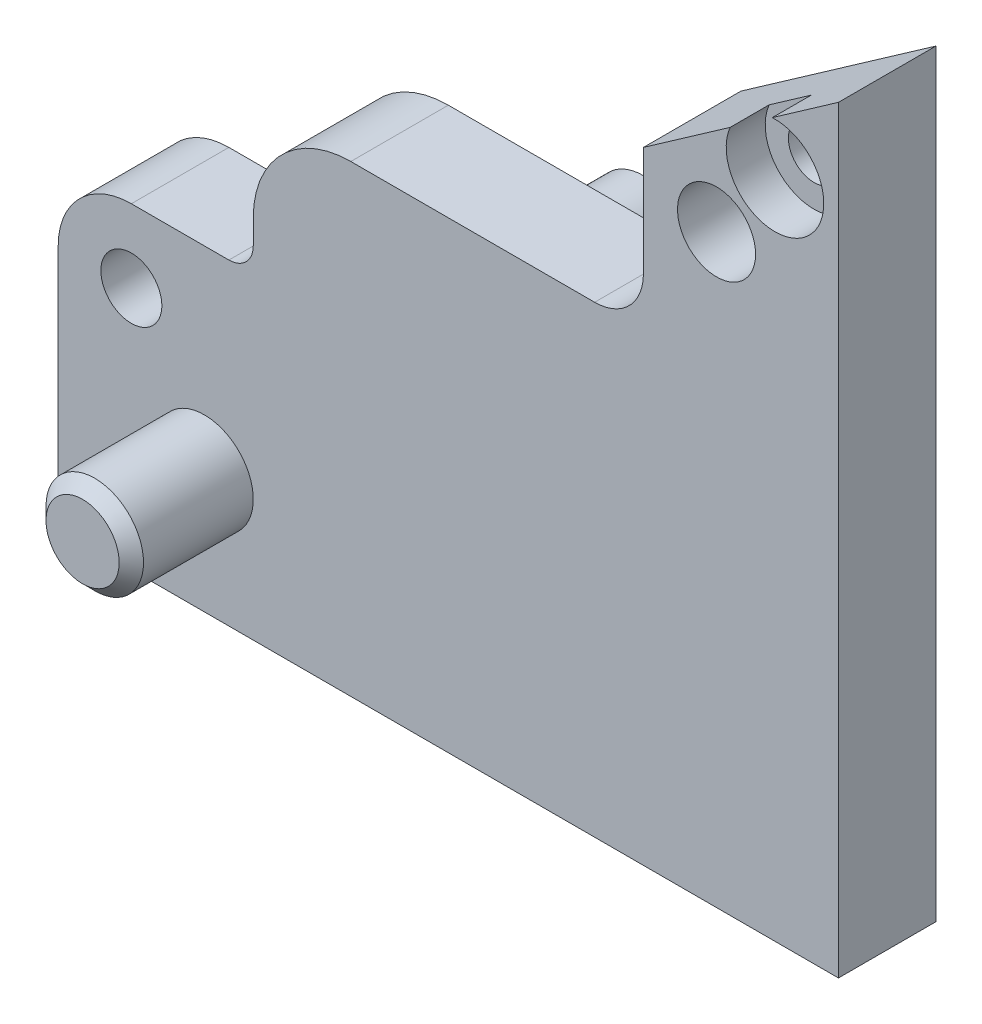
from build123d import *

# Parameters (mm, degrees)
SKETCH1_W                       = 32
SKETCH1_H                       = 31.101660306
BOSS_EXTRUDE1_DEPTH             = 4
SKETCH2_W                       = 8
SKETCH2_H                       = 18.101660306
CUT_EXTRUDE1_DEPTH              = 5
SKETCH3_W                       = 16
SKETCH3_H                       = 12.101660306
CUT_EXTRUDE2_DEPTH              = 5
DRAFT1_ANGLE                    = -35.000000002
SKETCH4_W                       = 2
SKETCH4_H                       = 5
SKETCH5_W                       = 2
SKETCH5_H                       = 5
F_3_2_3_2_DIAMETER_HOLE1_D      = 3.2
F_3_2_3_2_DIAMETER_HOLE1_DEPTH  = 9
F_2_5_2_5_DIAMETER_HOLE1_D      = 2.5
F_2_5_2_5_DIAMETER_HOLE1_DEPTH  = 9
M4X0_7_TAPPED_HOLE1_D           = 2.1
M4X0_7_TAPPED_HOLE1_DEPTH       = 9
M4X0_7_TAPPED_HOLE1_CBORE_D     = 4
M4X0_7_TAPPED_HOLE1_CBORE_DEPTH = 1.6
F_2_5_2_5_DIAMETER_HOLE2_D      = 2.5
F_2_5_2_5_DIAMETER_HOLE2_DEPTH  = 7.5
F_2_5_2_5_DIAMETER_HOLE2_TIP    = 0.751075774
CHAMFER1_SIZE                   = 0.5
FILLET1_R                       = 1
FILLET2_R                       = 2
FILLET3_R                       = 3
FILLET4_R                       = 4


with BuildPart() as part:
    # Sketch1 → Boss-Extrude1 (new body)
    with BuildSketch(Plane(origin=(0, 0, 0), x_dir=(-1, 0, 0), z_dir=(0, 0, -1))):
        with Locations((-16, 15.550830153)):
            Rectangle(SKETCH1_W, SKETCH1_H)
    extrude(amount=-BOSS_EXTRUDE1_DEPTH)

    # Sketch2 → Cut-Extrude1 (cut, through all)
    with BuildSketch(Plane.XY.offset(4)):
        with Locations((4, 22.050830153)):
            Rectangle(SKETCH2_W, SKETCH2_H)
    extrude(amount=-CUT_EXTRUDE1_DEPTH, mode=Mode.SUBTRACT)

    # Sketch3 → Cut-Extrude2 (cut, through all)
    with BuildSketch(Plane.XY.offset(4)):
        with Locations((16, 25.050830153)):
            Rectangle(SKETCH3_W, SKETCH3_H)
    extrude(amount=-CUT_EXTRUDE2_DEPTH, mode=Mode.SUBTRACT)

    # Draft1
    draft1_faces = [part.faces().sort_by_distance(p)[0] for p in [
        (28, 31.101660306, 2),
    ]]
    draft(draft1_faces, Plane(origin=(32, 31.101660306, 4), x_dir=(0, 0, 1), z_dir=(1, 0, 0)), DRAFT1_ANGLE)

    # Sketch4 → Revolve1 (revolve)
    with BuildSketch(Plane.XZ.offset(-5)):
        with Locations((7, 6.5)):
            Rectangle(SKETCH4_W, SKETCH4_H)
    revolve(axis=Axis((6, 5, 9), (0, 0, -1)))

    # Sketch5 → Revolve2 (revolve)
    with BuildSketch(Plane(origin=(0, 14, 0), x_dir=(1, 0, 0), z_dir=(0, 1, 0))):
        with Locations((16.5, 2.5)):
            Rectangle(SKETCH5_W, SKETCH5_H)
    revolve(axis=Axis((15.5, 14, -5), (0, 0, 1)))

    # Ø3.2 (3.2) Diameter Hole1
    with Locations(Plane.XY.offset(4)):
        with Locations((27, 24)):
            Hole(F_3_2_3_2_DIAMETER_HOLE1_D / 2, depth=F_3_2_3_2_DIAMETER_HOLE1_DEPTH)

    # Ø2.5 (2.5) Diameter Hole1
    with Locations(Plane(origin=(0, 0, 0), x_dir=(-1, 0, 0), z_dir=(0, 0, -1))):
        with Locations((-3, 10)):
            Hole(F_2_5_2_5_DIAMETER_HOLE1_D / 2, depth=F_2_5_2_5_DIAMETER_HOLE1_DEPTH)

    # M4x0.7 Tapped Hole1
    with Locations(Plane.XY.offset(4)):
        with Locations((29.395995182, 27.202999702)):
            CounterBoreHole(M4X0_7_TAPPED_HOLE1_D / 2, M4X0_7_TAPPED_HOLE1_CBORE_D / 2, M4X0_7_TAPPED_HOLE1_CBORE_DEPTH, depth=M4X0_7_TAPPED_HOLE1_DEPTH)

    # Ø2.5 (2.5) Diameter Hole2
    with Locations(Plane(origin=(0, 0, 0), x_dir=(-1, 0, 0), z_dir=(0, -1, 0))):
        with Locations((-10, -2), (-19.5, -2), (-29, -2)):
            Hole(F_2_5_2_5_DIAMETER_HOLE2_D / 2, depth=F_2_5_2_5_DIAMETER_HOLE2_DEPTH)
            with Locations((0, 0, -(F_2_5_2_5_DIAMETER_HOLE2_DEPTH + F_2_5_2_5_DIAMETER_HOLE2_TIP / 2))):  # 118° drill point
                Cone(0, F_2_5_2_5_DIAMETER_HOLE2_D / 2, F_2_5_2_5_DIAMETER_HOLE2_TIP, mode=Mode.SUBTRACT)

    # Chamfer1
    chamfer1_edges = [part.edges().sort_by_distance(p)[0] for p in [
        (4, 5, 9),
        (13.5, 14, -5),
    ]]
    chamfer(chamfer1_edges, length=CHAMFER1_SIZE)

    # Fillet1
    fillet1_edges = [part.edges().sort_by_distance(p)[0] for p in [
        (8, 13, 2),
    ]]
    fillet(fillet1_edges, radius=FILLET1_R)

    # Fillet2
    fillet2_edges = [part.edges().sort_by_distance(p)[0] for p in [
        (24, 19, 2),
    ]]
    fillet(fillet2_edges, radius=FILLET2_R)

    # Fillet3
    fillet3_edges = [part.edges().sort_by_distance(p)[0] for p in [
        (0, 13, 2),
    ]]
    fillet(fillet3_edges, radius=FILLET3_R)

    # Fillet4
    fillet4_edges = [part.edges().sort_by_distance(p)[0] for p in [
        (8, 19, 2),
    ]]
    fillet(fillet4_edges, radius=FILLET4_R)


solid = part.part
